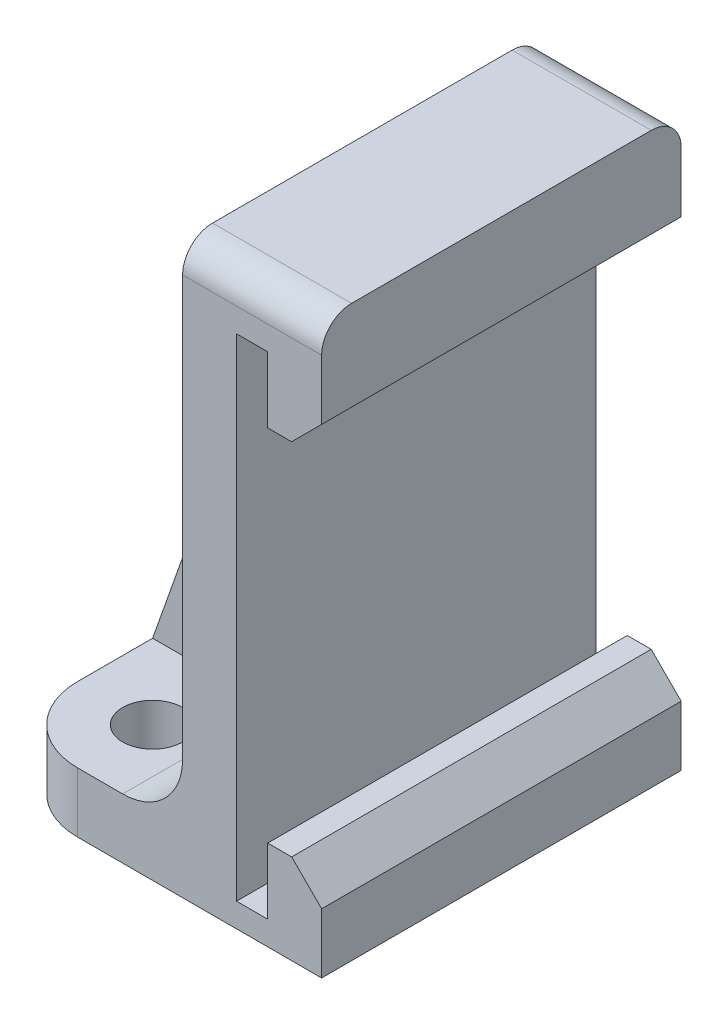
from build123d import *

# Parameters (mm, degrees)
BOSS_EXTRUDE1_DEPTH = 9.525
FILLET1_R           = 3.175
BOSS_EXTRUDE2_DEPTH = 1.5875
SKETCH3_R           = 1.5875
CUT_EXTRUDE1_DEPTH  = 3.175
CHAMFER1_SIZE       = 1.5875
FILLET2_R           = 1.5875
FILLET3_R           = 3.9624


with BuildPart() as part:
    # Sketch1 → Boss-Extrude1 (new body, symmetric)
    with BuildSketch(Plane.XY):
        Polygon((-0.3175, -0.3175), (-0.3175, 25.7175), (1.3335, 25.7175), (1.3335, 22.225), (4.191, 22.225), (4.191, 28.575), (1.016, 28.575), (-3.175, 28.575), (-3.175, 1.5875), (-12.7, 1.5875), (-12.7, -1.5875), (-3.175, -1.5875), (4.191, -1.5875), (4.191, 0), (4.191, 3.175), (1.3335, 3.175), (1.3335, -0.3175), align=None)
    extrude(amount=BOSS_EXTRUDE1_DEPTH, both=True)

    # Fillet1
    fillet1_edges = [part.edges().sort_by_distance(p)[0] for p in [
        (-3.175, 1.5875, 0),
    ]]
    fillet(fillet1_edges, radius=FILLET1_R)

    # Sketch2 → Boss-Extrude2 (add, symmetric)
    with BuildSketch(Plane.XY):
        Polygon((-3.175, 28.575), (-12.7, 1.5875), (-3.175, 1.5875), align=None)
    extrude(amount=BOSS_EXTRUDE2_DEPTH, both=True)

    # Sketch3 → Cut-Extrude1 (cut)
    with BuildSketch(Plane(origin=(0, 1.5875, 0), x_dir=(1, 0, 0), z_dir=(0, 1, 0))):
        with Locations((-8.73125, -5.55625)):
            Circle(SKETCH3_R)
        with Locations((-8.73125, 5.55625)):
            Circle(SKETCH3_R)
    extrude(amount=-CUT_EXTRUDE1_DEPTH, mode=Mode.SUBTRACT)

    # Chamfer1
    chamfer1_edges = [part.edges().sort_by_distance(p)[0] for p in [
        (4.191, 3.175, 0),
        (4.191, 22.225, 0),
    ]]
    chamfer(chamfer1_edges, length=CHAMFER1_SIZE)

    # Fillet2
    fillet2_edges = [part.edges().sort_by_distance(p)[0] for p in [
        (0.508, 28.575, -9.525),
        (0.508, 28.575, 9.525),
    ]]
    fillet(fillet2_edges, radius=FILLET2_R)

    # Fillet3
    fillet3_edges = [part.edges().sort_by_distance(p)[0] for p in [
        (-12.7, 0, -9.525),
        (-12.7, 0, 9.525),
    ]]
    fillet(fillet3_edges, radius=FILLET3_R)


solid = part.part
